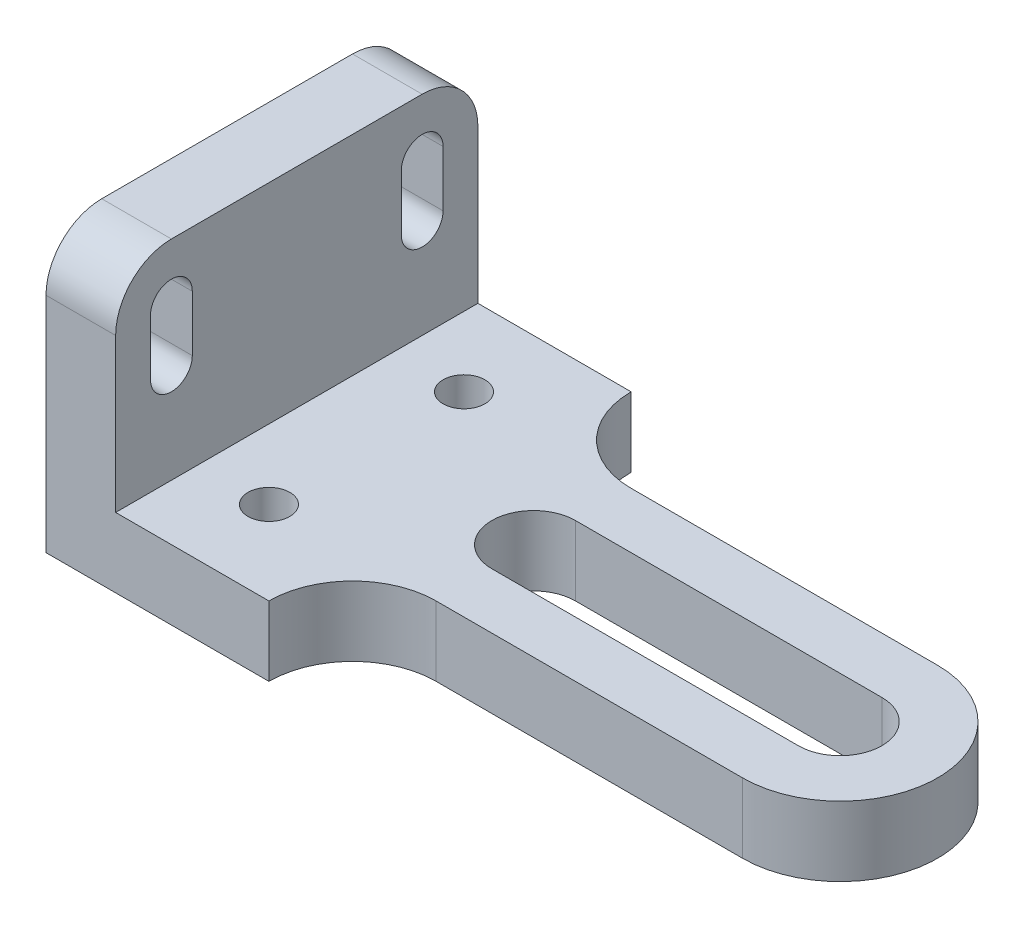
from build123d import *

# Parameters (mm, degrees)
BOSS_EXTRUDE1_DEPTH = 10
SKETCH2_R           = 3
BOSS_EXTRUDE2_DEPTH = 10


with BuildPart() as part:
    # Sketch1 → Boss-Extrude1 (new body)
    with BuildSketch(Plane(origin=(0, 0, 0), x_dir=(0, 0, -1), z_dir=(1, 0, 0))):
        with BuildLine():
            Line((-26, 0), (26, 0))
            Line((26, 0), (26, 32))
            ThreePointArc((26, 32), (23.656854249, 37.656854249), (18, 40))
            Line((18, 40), (-18, 40))
            ThreePointArc((-18, 40), (-23.656854249, 37.656854249), (-26, 32))
            Line((-26, 32), (-26, 0))
        make_face()
        with BuildLine():
            Line((-15, 32), (-15, 24))
            ThreePointArc((-15, 24), (-18, 21), (-21, 24))
            Line((-21, 24), (-21, 32))
            ThreePointArc((-21, 32), (-18, 35), (-15, 32))
        make_face(mode=Mode.SUBTRACT)
        with BuildLine():
            Line((15, 32), (15, 24))
            ThreePointArc((15, 24), (18, 21), (21, 24))
            Line((21, 24), (21, 32))
            ThreePointArc((21, 32), (18, 35), (15, 32))
        make_face(mode=Mode.SUBTRACT)
    extrude(amount=BOSS_EXTRUDE1_DEPTH)

    # Sketch2 → Boss-Extrude2 (add)
    with BuildSketch(Plane(origin=(0, 0, 0), x_dir=(1, 0, 0), z_dir=(0, 1, 0))):
        with BuildLine():
            Line((0, 26), (32, 26))
            ThreePointArc((32, 26), (35.514718626, 17.514718626), (44, 14))
            Line((44, 14), (88, 14))
            ThreePointArc((88, 14), (102, 0), (88, -14))
            Line((88, -14), (44, -14))
            ThreePointArc((44, -14), (35.514718626, -17.514718626), (32, -26))
            Line((32, -26), (0, -26))
            Line((0, -26), (0, 26))
        make_face()
        with Locations((20, 14)):
            Circle(SKETCH2_R, mode=Mode.SUBTRACT)
        with Locations((20, -14)):
            Circle(SKETCH2_R, mode=Mode.SUBTRACT)
        with BuildLine():
            Line((44, 6), (88, 6))
            ThreePointArc((88, 6), (94, 0), (88, -6))
            Line((88, -6), (44, -6))
            ThreePointArc((44, -6), (38, 0), (44, 6))
        make_face(mode=Mode.SUBTRACT)
    extrude(amount=BOSS_EXTRUDE2_DEPTH)


solid = part.part
